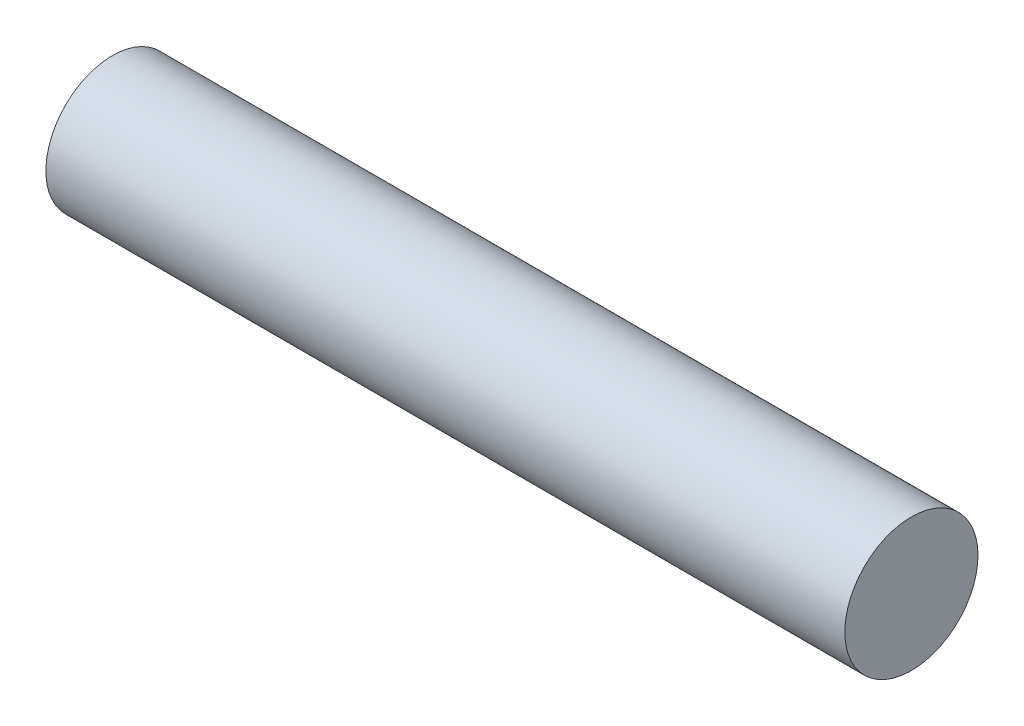
from build123d import *

# Parameters (mm, degrees)
SKETCH1_R           = 5
BOSS_EXTRUDE1_DEPTH = 60


with BuildPart() as part:
    # Sketch1 → Boss-Extrude1 (new body)
    with BuildSketch(Plane(origin=(0, 0, 0), x_dir=(0, 0, -1), z_dir=(1, 0, 0))):
        Circle(SKETCH1_R)
    extrude(amount=BOSS_EXTRUDE1_DEPTH)


solid = part.part
